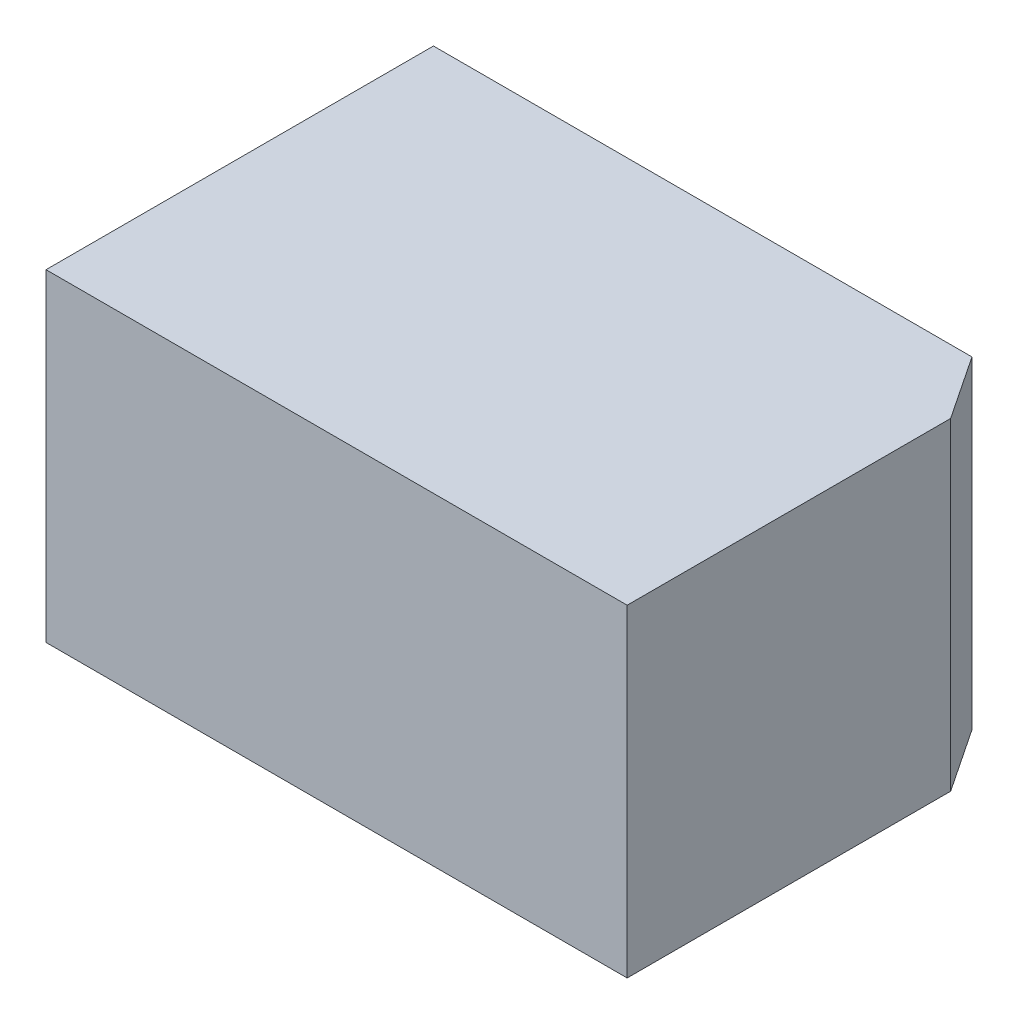
from build123d import *

# Parameters (mm, degrees)
SKETCH1_W           = 9
SKETCH1_H           = 6
BOSS_EXTRUDE1_DEPTH = 5
SKETCH3_R           = 1.25
CUT_EXTRUDE2_DEPTH  = 4
SKETCH2_R           = 0.795
CUT_EXTRUDE1_DEPTH  = 1
CUT_EXTRUDE3_DEPTH  = 6


with BuildPart() as part:
    # Sketch1 → Boss-Extrude1 (new body)
    with BuildSketch(Plane(origin=(0, 0, 0), x_dir=(1, 0, 0), z_dir=(0, 1, 0))):
        Rectangle(SKETCH1_W, SKETCH1_H)
    extrude(amount=BOSS_EXTRUDE1_DEPTH)

    # Sketch3 → Cut-Extrude2 (cut)
    with BuildSketch(Plane.XZ):
        with Locations((-1.5, 0)):
            Circle(SKETCH3_R)
    extrude(amount=-CUT_EXTRUDE2_DEPTH, mode=Mode.SUBTRACT)

    # Sketch2 → Cut-Extrude1 (cut)
    with BuildSketch(Plane.XZ):
        with Locations((-3.25, -1.875)):
            Circle(SKETCH2_R)
        with Locations((-3.25, 1.875)):
            Circle(SKETCH2_R)
        with Locations((1.5, 0)):
            Circle(SKETCH2_R)
    extrude(amount=-CUT_EXTRUDE1_DEPTH, mode=Mode.SUBTRACT)

    # Sketch4 → Cut-Extrude3 (cut, through all)
    with BuildSketch(Plane.XZ):
        Polygon((3.839906766, -3), (4.5, -2.00986015), (4.5, -3), align=None)
    extrude(amount=-CUT_EXTRUDE3_DEPTH, mode=Mode.SUBTRACT)


solid = part.part
